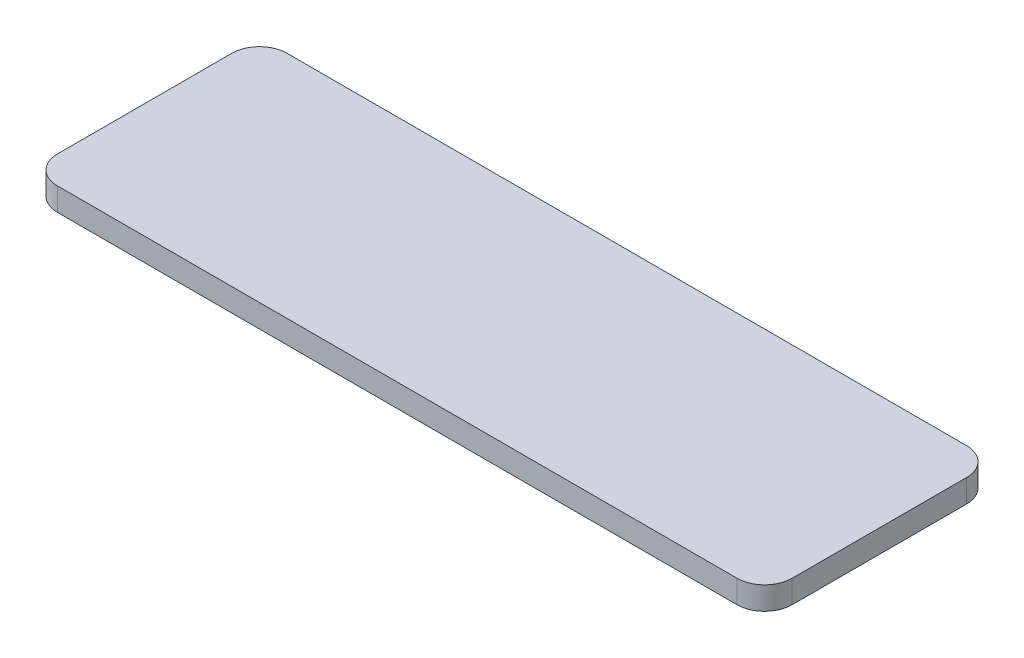
from build123d import *

# Parameters (mm, degrees)
BOSS_EXTRUDE1_DEPTH = 5


with BuildPart() as part:
    # Sketch1 → Boss-Extrude1 (new body)
    with BuildSketch(Plane(origin=(0, 0, 0), x_dir=(1, 0, 0), z_dir=(0, 1, 0))):
        with BuildLine():
            Line((0, 0), (148, 0))
            ThreePointArc((148, 0), (152.242640687, -1.757359313), (154, -6))
            Line((154, -6), (154, -44))
            ThreePointArc((154, -44), (152.242640687, -48.242640687), (148, -50))
            Line((148, -50), (0, -50))
            ThreePointArc((0, -50), (-4.242640687, -48.242640687), (-6, -44))
            Line((-6, -44), (-6, -6))
            ThreePointArc((-6, -6), (-4.242640687, -1.757359313), (0, 0))
        make_face()
    extrude(amount=BOSS_EXTRUDE1_DEPTH)


solid = part.part
